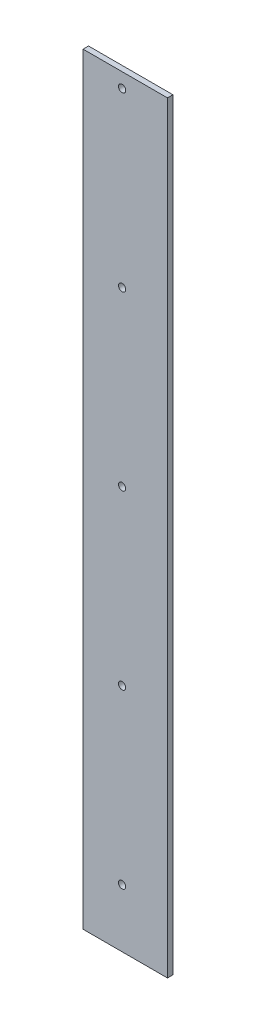
from build123d import *

# Parameters (mm, degrees)
SKETCH1_W           = 46.5
SKETCH1_H           = 420
SKETCH1_R           = 2
BOSS_EXTRUDE1_DEPTH = 3


with BuildPart() as part:
    # Sketch1 → Boss-Extrude1 (new body)
    with BuildSketch(Plane.XY):
        with Locations((0.557942617, -6.721028691)):
            Rectangle(SKETCH1_W, SKETCH1_H)
        with Locations((-1.192057383, 195.278971308)):
            Circle(SKETCH1_R, mode=Mode.SUBTRACT)
        with Locations((-1.192057383, 100.278971308)):
            Circle(SKETCH1_R, mode=Mode.SUBTRACT)
        with Locations((-1.192057383, 5.278971308)):
            Circle(SKETCH1_R, mode=Mode.SUBTRACT)
        with Locations((-1.192057383, -89.721028692)):
            Circle(SKETCH1_R, mode=Mode.SUBTRACT)
        with Locations((-1.192057383, -184.721028692)):
            Circle(SKETCH1_R, mode=Mode.SUBTRACT)
    extrude(amount=BOSS_EXTRUDE1_DEPTH)


solid = part.part
